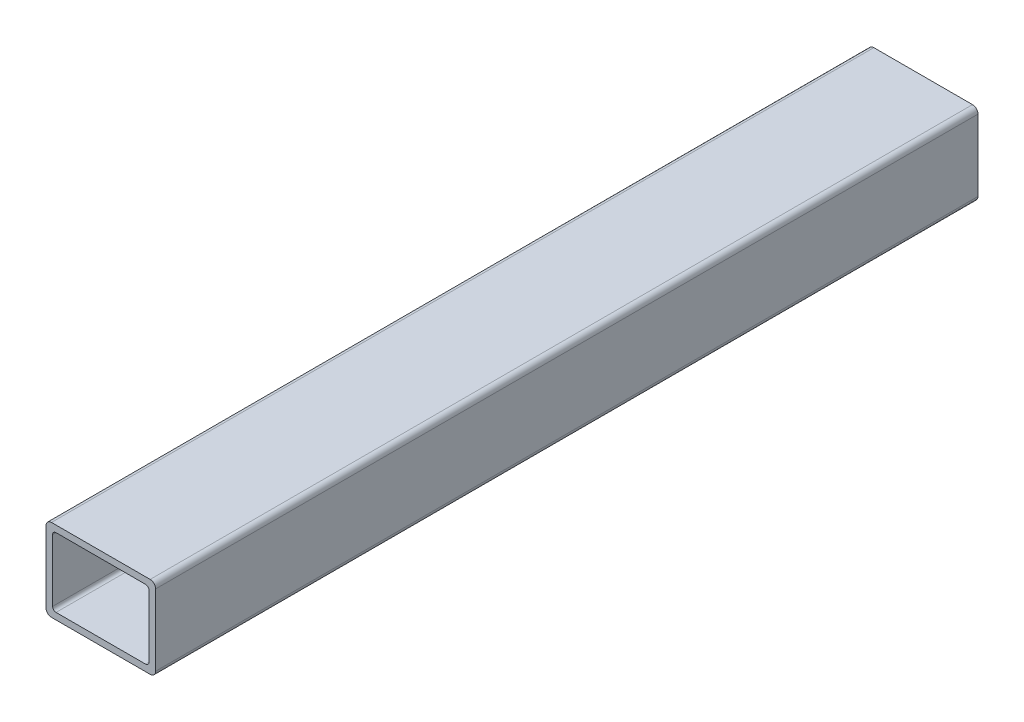
from build123d import *

# Parameters (mm, degrees)
BOSS_EXTRUDE1_DEPTH = 381


with BuildPart() as part:
    # Sketch4 → Boss-Extrude1 (new body)
    with BuildSketch(Plane.XY):
        with BuildLine():
            Line((25.4, -16.51), (25.4, 16.51))
            ThreePointArc((25.4, 16.51), (24.656051224, 18.306051224), (22.86, 19.05))
            Line((22.86, 19.05), (-22.86, 19.05))
            ThreePointArc((-22.86, 19.05), (-24.656051224, 18.306051224), (-25.4, 16.51))
            Line((-25.4, 16.51), (-25.4, -16.51))
            ThreePointArc((-25.4, -16.51), (-24.656051224, -18.306051224), (-22.86, -19.05))
            Line((-22.86, -19.05), (22.86, -19.05))
            ThreePointArc((22.86, -19.05), (24.656051224, -18.306051224), (25.4, -16.51))
        make_face()
        with BuildLine():
            Line((22.352, 14.4018), (22.352, -14.4018))
            ThreePointArc((22.352, -14.4018), (21.883312271, -15.533312271), (20.7518, -16.002))
            Line((20.7518, -16.002), (-20.7518, -16.002))
            ThreePointArc((-20.7518, -16.002), (-21.883312271, -15.533312271), (-22.352, -14.4018))
            Line((-22.352, -14.4018), (-22.352, 14.4018))
            ThreePointArc((-22.352, 14.4018), (-21.883312271, 15.533312271), (-20.7518, 16.002))
            Line((-20.7518, 16.002), (20.7518, 16.002))
            ThreePointArc((20.7518, 16.002), (21.883312271, 15.533312271), (22.352, 14.4018))
        make_face(mode=Mode.SUBTRACT)
    extrude(amount=BOSS_EXTRUDE1_DEPTH)


solid = part.part
